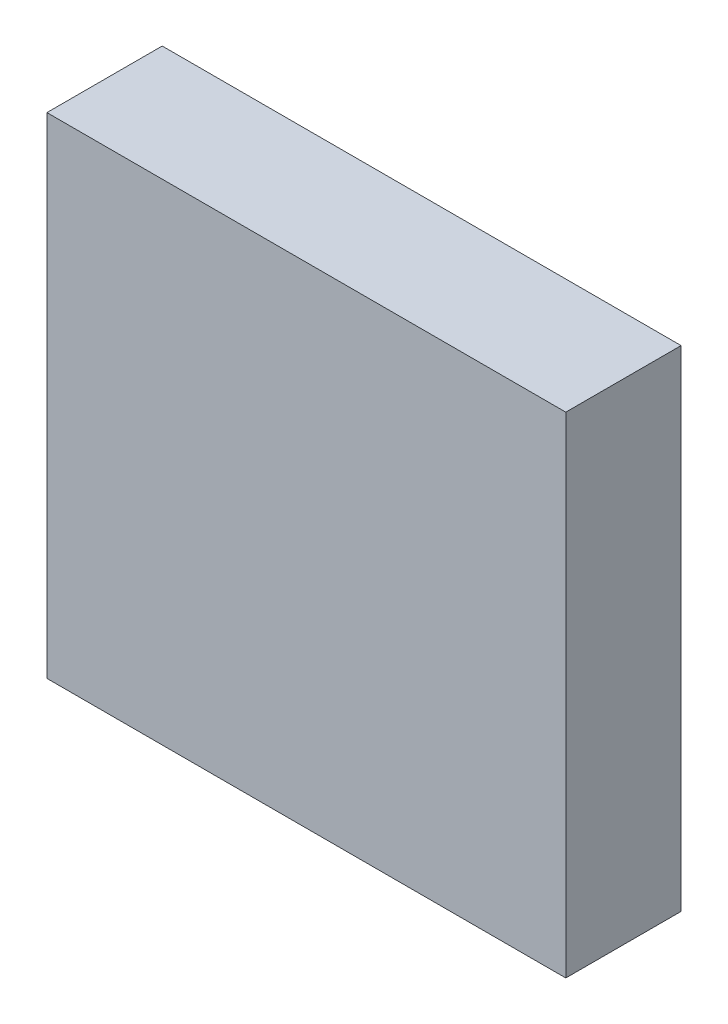
from build123d import *

# Parameters (mm, degrees)
SKETCH1_W           = 90
SKETCH1_H           = 85
BOSS_EXTRUDE1_DEPTH = 20


with BuildPart() as part:
    # Sketch1 → Boss-Extrude1 (new body)
    with BuildSketch(Plane.XY):
        with Locations((106.927827201, -21.89715693)):
            Rectangle(SKETCH1_W, SKETCH1_H)
    extrude(amount=BOSS_EXTRUDE1_DEPTH)


solid = part.part
